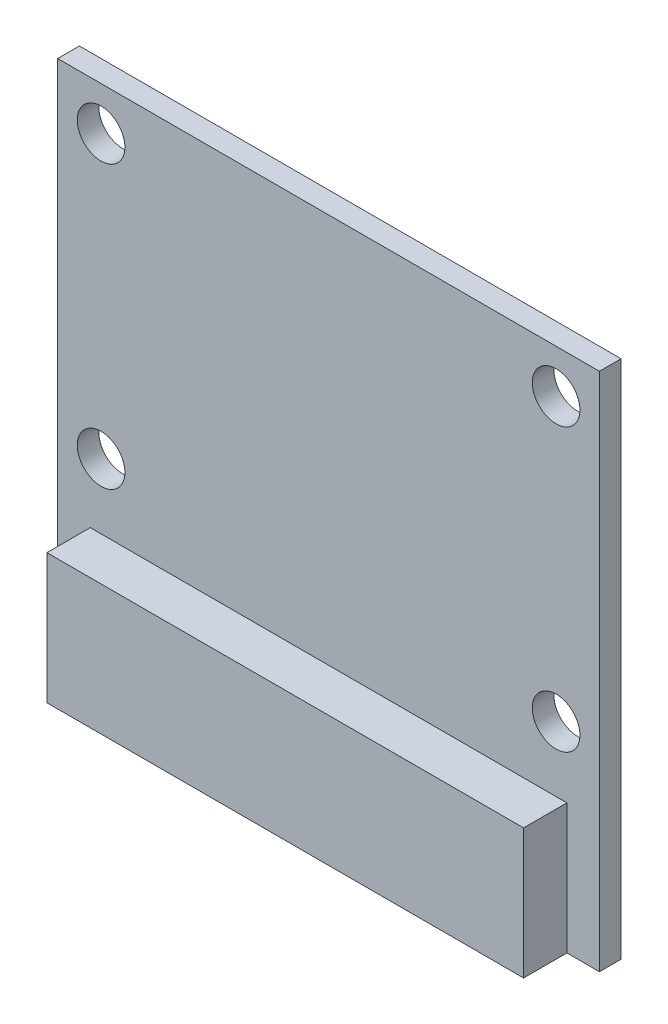
from build123d import *

# Parameters (mm, degrees)
SKETCH_1_W      = 25
SKETCH_1_H      = 24
SKETCH_1_R      = 1.1
EXTRUDE_1_DEPTH = 1
SKETCH_2_W      = 22
SKETCH_2_H      = 6
EXTRUDE_2_DEPTH = 2
SKETCH_3_W      = 9
SKETCH_3_H      = 9
EXTRUDE_3_DEPTH = 2.5
SKETCH_4_R      = 3.5
EXTRUDE_4_DEPTH = 1.5
SKETCH_5_W      = 7
SKETCH_5_H      = 7
EXTRUDE_5_DEPTH = 1


with BuildPart() as part:
    # 草图1 → 凸台-拉伸1 (new body)
    with BuildSketch(Plane.XY):
        Rectangle(SKETCH_1_W, SKETCH_1_H)
        with Locations((-10.5, 10)):
            Circle(SKETCH_1_R, mode=Mode.SUBTRACT)
        with Locations((-10.5, -3)):
            Circle(SKETCH_1_R, mode=Mode.SUBTRACT)
        with Locations((10.5, -3)):
            Circle(SKETCH_1_R, mode=Mode.SUBTRACT)
        with Locations((10.5, 10)):
            Circle(SKETCH_1_R, mode=Mode.SUBTRACT)
    extrude(amount=EXTRUDE_1_DEPTH)

    # 草图2 → 凸台-拉伸2 (add)
    with BuildSketch(Plane.XY.offset(1)):
        with Locations((0, -9)):
            Rectangle(SKETCH_2_W, SKETCH_2_H)
    extrude(amount=EXTRUDE_2_DEPTH)

    # 草图3 → 凸台-拉伸3 (add)
    with BuildSketch(Plane(origin=(0, 0, 0), x_dir=(-1, 0, 0), z_dir=(0, 0, -1))):
        with Locations((0, -2.5)):
            Rectangle(SKETCH_3_W, SKETCH_3_H)
    extrude(amount=EXTRUDE_3_DEPTH)

    # 草图4 → 凸台-拉伸4 (add)
    with BuildSketch(Plane(origin=(0, 0, -2.5), x_dir=(-1, 0, 0), z_dir=(0, 0, -1))):
        with Locations((0, -2.5)):
            Circle(SKETCH_4_R)
    extrude(amount=EXTRUDE_4_DEPTH)

    # 草图5 → 凸台-拉伸5 (add)
    with BuildSketch(Plane(origin=(0, 0, 0), x_dir=(-1, 0, 0), z_dir=(0, 0, -1))):
        with Locations((0, 5.5)):
            Rectangle(SKETCH_5_W, SKETCH_5_H)
    extrude(amount=EXTRUDE_5_DEPTH)


solid = part.part
